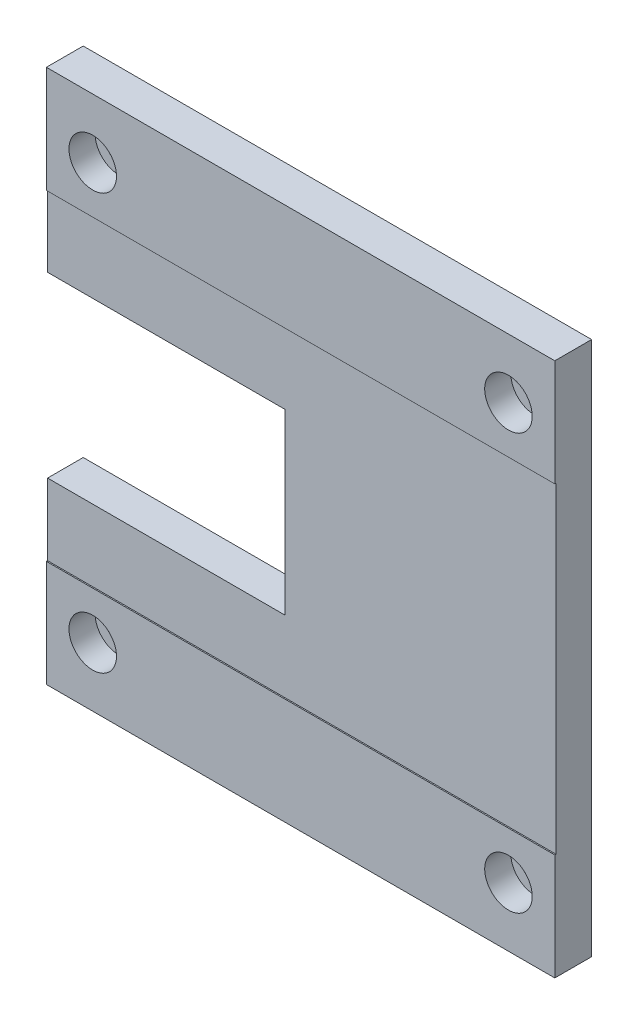
from build123d import *

# Parameters (mm, degrees)
SKETCH_1_W                   = 85.6
SKETCH_1_H                   = 90
EXTRUDE_1_DEPTH              = 6
SKETCH_2_W                   = 85.6
SKETCH_2_H                   = 17.95
EXTRUDE_2_DEPTH              = 0.2
SKETCH_3_W                   = 40
SKETCH_3_H                   = 30
CUT_EXTRUDE_1_DEPTH          = 7
HOLE_WIZARD_M4_1_D           = 4.5
HOLE_WIZARD_M4_1_CBORE_D     = 8
HOLE_WIZARD_M4_1_CBORE_DEPTH = 4.4


with BuildPart() as part:
    # 草图1 → 凸台-拉伸1 (new body)
    with BuildSketch(Plane.XY):
        with Locations((42.8, 45)):
            Rectangle(SKETCH_1_W, SKETCH_1_H)
    extrude(amount=EXTRUDE_1_DEPTH)

    # 草图2 → 凸台-拉伸2 (add)
    with BuildSketch(Plane.XY.offset(6)):
        with Locations((42.8, 81.025)):
            Rectangle(SKETCH_2_W, SKETCH_2_H)
        with Locations((42.8, 8.975)):
            Rectangle(SKETCH_2_W, SKETCH_2_H)
    extrude(amount=EXTRUDE_2_DEPTH)

    # 草图3 → 切除-拉伸1 (cut, through all)
    with BuildSketch(Plane.XY.offset(6)):
        with Locations((20, 45)):
            Rectangle(SKETCH_3_W, SKETCH_3_H)
    extrude(amount=-CUT_EXTRUDE_1_DEPTH, mode=Mode.SUBTRACT)

    # M4 六角凹头螺钉的柱形沉头孔1 (through all)
    with Locations(Plane.XY.offset(6.2)):
        with Locations((77.8, 80), (7.8, 80), (7.8, 10), (77.8, 10)):
            CounterBoreHole(HOLE_WIZARD_M4_1_D / 2, HOLE_WIZARD_M4_1_CBORE_D / 2, HOLE_WIZARD_M4_1_CBORE_DEPTH)


solid = part.part
